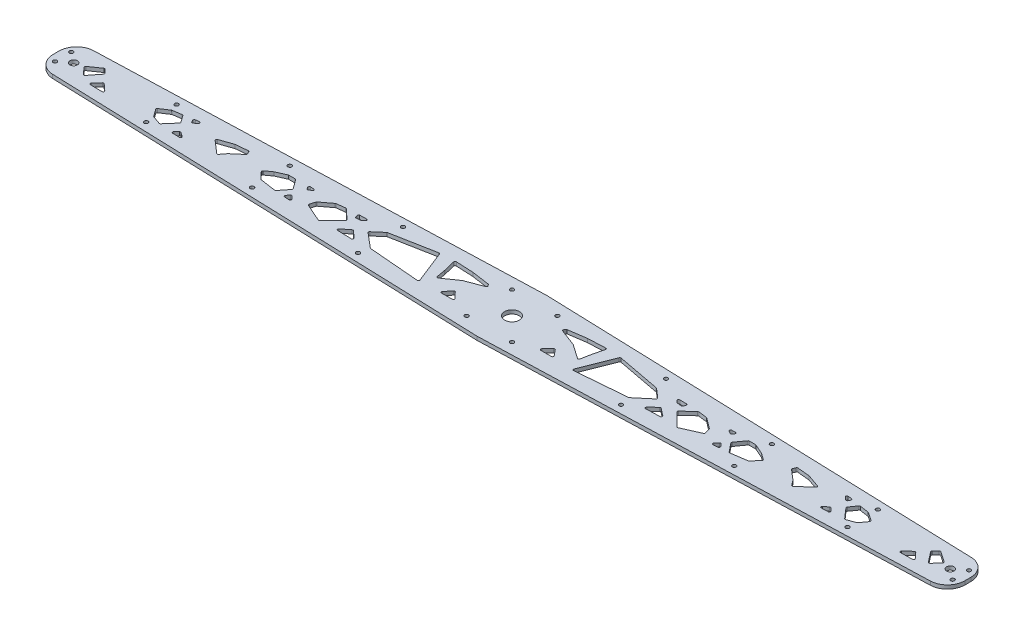
from build123d import *

# Parameters (mm, degrees)
BOSS_EXTRUDE1_DEPTH = 3.18
SKETCH3_R           = 6.35
SKETCH3_R_2         = 3.175
SKETCH3_R_3         = 1.65
CUT_EXTRUDE1_DEPTH  = 4.18
CUT_EXTRUDE8_DEPTH  = 4.18


with BuildPart() as part:
    # Sketch2 → Boss-Extrude1 (new body)
    with BuildSketch(Plane(origin=(0, 0, 0), x_dir=(1, 0, 0), z_dir=(0, 1, 0))):
        with BuildLine():
            Line((-375, 17.5), (0, 30))
            Line((0, 30), (375, 17.5))
            Line((375, 17.5), (375.499722453, 17.483342585))
            ThreePointArc((375.499722453, 17.483342585), (385.781832794, 12.920095592), (390, 2.49166898))
            Line((390, 2.49166898), (390, -2.49166898))
            ThreePointArc((390, -2.49166898), (385.781832794, -12.920095592), (375.499722453, -17.483342585))
            Line((375.499722453, -17.483342585), (375, -17.5))
            Line((375, -17.5), (0, -30))
            Line((0, -30), (-375, -17.5))
            Line((-375, -17.5), (-375.499722453, -17.483342585))
            ThreePointArc((-375.499722453, -17.483342585), (-385.781832794, -12.920095592), (-390, -2.49166898))
            Line((-390, -2.49166898), (-390, 2.49166898))
            ThreePointArc((-390, 2.49166898), (-385.781832794, 12.920095592), (-375.499722453, 17.483342585))
            Line((-375.499722453, 17.483342585), (-375, 17.5))
        make_face()
    extrude(amount=BOSS_EXTRUDE1_DEPTH)

    # Sketch3 → Cut-Extrude1 (cut, through all)
    with BuildSketch(Plane(origin=(0, 3.18, 0), x_dir=(1, 0, 0), z_dir=(0, 1, 0))):
        Circle(SKETCH3_R)
        with Locations((-375, 0)):
            Circle(SKETCH3_R_2)
        with Locations((-206.25, 16.125)):
            Circle(SKETCH3_R_3)
        with Locations((-112.5, -19.25)):
            Circle(SKETCH3_R_3)
        with Locations((375, 0)):
            Circle(SKETCH3_R_2)
        with Locations((-112.5, 19.25)):
            Circle(SKETCH3_R_3)
        with Locations((-206.25, -16.125)):
            Circle(SKETCH3_R_3)
        with Locations((112.5, -19.25)):
            Circle(SKETCH3_R_3)
        with Locations((112.5, 19.25)):
            Circle(SKETCH3_R_3)
        with Locations((206.25, -16.125)):
            Circle(SKETCH3_R_3)
        with Locations((206.25, 16.125)):
            Circle(SKETCH3_R_3)
        with Locations((-384, 7)):
            Circle(SKETCH3_R_3)
        with Locations((-384, -7)):
            Circle(SKETCH3_R_3)
        with Locations((384, -7)):
            Circle(SKETCH3_R_3)
        with Locations((384, 7)):
            Circle(SKETCH3_R_3)
        with Locations((-19.420687745, 19.420687745)):
            Circle(SKETCH3_R_3)
        with Locations((-19.420687745, -19.420687745)):
            Circle(SKETCH3_R_3)
        with Locations((19.420687745, -19.420687745)):
            Circle(SKETCH3_R_3)
        with Locations((19.420687745, 19.420687745)):
            Circle(SKETCH3_R_3)
        with Locations((-300, 13)):
            Circle(SKETCH3_R_3)
        with Locations((-300, -13)):
            Circle(SKETCH3_R_3)
        with Locations((300, -13)):
            Circle(SKETCH3_R_3)
        with Locations((300, 13)):
            Circle(SKETCH3_R_3)
    extrude(amount=-CUT_EXTRUDE1_DEPTH, mode=Mode.SUBTRACT)

    # Sketch11 → Cut-Extrude8 (cut, through all)
    with BuildSketch(Plane(origin=(0, 3.18, 0), x_dir=(1, 0, 0), z_dir=(0, 1, 0))):
        with BuildLine():
            Line((-46.955749346, -13.254199403), (-37.87504075, -13.254199403))
            ThreePointArc((-37.87504075, -13.254199403), (-36.95455324, -12.644971387), (-37.155639289, -11.559604889))
            Line((-37.155639289, -11.559604889), (-42.067554645, -6.472263986))
            ThreePointArc((-42.067554645, -6.472263986), (-42.827630249, -6.167686035), (-43.560434546, -6.533035888))
            Line((-43.560434546, -6.533035888), (-47.729227786, -11.620376792))
            ThreePointArc((-47.729227786, -11.620376792), (-47.859580804, -12.68208805), (-46.955749346, -13.254199403))
        make_face()
        with BuildLine():
            Line((-59.536816501, -3.515356838), (-47.468549241, 4.898167025))
            ThreePointArc((-47.468549241, 4.898167025), (-47.363497956, 4.962180575), (-47.251381641, 5.012810987))
            Line((-47.251381641, 5.012810987), (-32.914496504, 10.452279602))
            ThreePointArc((-32.914496504, 10.452279602), (-32.313794994, 11.092037289), (-32.44890253, 11.959146368))
            Line((-32.44890253, 11.959146368), (-33.152492574, 12.968368286))
            ThreePointArc((-33.152492574, 12.968368286), (-33.448046335, 13.247713619), (-33.830389761, 13.386275322))
            Line((-33.830389761, 13.386275322), (-49.020035845, 15.571979867))
            ThreePointArc((-49.020035845, 15.571979867), (-49.06816555, 15.57771866), (-49.116516797, 15.58111852))
            Line((-49.116516797, 15.58111852), (-63.942588973, 16.263044091))
            ThreePointArc((-63.942588973, 16.263044091), (-64.760029141, 15.900337127), (-64.960455814, 15.028790273))
            Line((-64.960455814, 15.028790273), (-62.531576105, 4.996583503))
            ThreePointArc((-62.531576105, 4.996583503), (-62.52527538, 4.968839122), (-62.519766476, 4.940926727))
            Line((-62.519766476, 4.940926727), (-61.092444735, -2.874685387))
            ThreePointArc((-61.092444735, -2.874685387), (-60.48952482, -3.619685515), (-59.536816501, -3.515356838))
        make_face()
        with BuildLine():
            Line((-65.867489279, -12.851084643), (-76.818791516, 14.810968515))
            ThreePointArc((-76.818791516, 14.810968515), (-77.266092019, 15.318773143), (-77.93434379, 15.42546359))
            Line((-77.93434379, 15.42546359), (-114.979478259, 8.421844862))
            ThreePointArc((-114.979478259, 8.421844862), (-115.227740664, 8.340150133), (-115.44635537, 8.196916545))
            Line((-115.44635537, 8.196916545), (-123.167009838, 1.546451805))
            ThreePointArc((-123.167009838, 1.546451805), (-123.514354617, 0.783798146), (-123.159419133, 0.024647435))
            Line((-123.159419133, 0.024647435), (-110.862565184, -10.35581369))
            ThreePointArc((-110.862565184, -10.35581369), (-110.599754836, -10.515737447), (-110.300767263, -10.588203424))
            Line((-110.300767263, -10.588203424), (-66.880530036, -14.21571199))
            ThreePointArc((-66.880530036, -14.21571199), (-65.994339866, -13.81524887), (-65.867489279, -12.851084643))
        make_face()
        with BuildLine():
            Line((-138.500363881, -9.512051857), (-132.205638285, -4.609617592))
            ThreePointArc((-132.205638285, -4.609617592), (-131.548188505, -4.399497492), (-130.911222966, -4.665327458))
            Line((-130.911222966, -4.665327458), (-125.244008956, -9.920736989))
            ThreePointArc((-125.244008956, -9.920736989), (-124.998535496, -11.032881643), (-125.953468681, -11.653547063))
            Line((-125.953468681, -11.653547063), (-137.915408287, -11.300571796))
            ThreePointArc((-137.915408287, -11.300571796), (-138.836369454, -10.611864392), (-138.500363881, -9.512051857))
        make_face()
        with BuildLine():
            Line((-139.739839999, 9.466665143), (-133.930891567, 9.592555667))
            ThreePointArc((-133.930891567, 9.592555667), (-132.974208512, 8.947395111), (-133.262475942, 7.83008741))
            Line((-133.262475942, 7.83008741), (-134.995827799, 6.360257908))
            ThreePointArc((-134.995827799, 6.360257908), (-135.241086847, 6.207097438), (-135.519914513, 6.130512433))
            Line((-135.519914513, 6.130512433), (-138.979079647, 5.70297517))
            ThreePointArc((-138.979079647, 5.70297517), (-139.629939754, 5.846302376), (-140.046194638, 6.366776619))
            Line((-140.046194638, 6.366776619), (-140.662626079, 8.138252861))
            ThreePointArc((-140.662626079, 8.138252861), (-140.539462824, 9.037411465), (-139.739839999, 9.466665143))
        make_face()
        with BuildLine():
            Line((-141.869121283, 0.703843181), (-150.293270264, 8.561291761))
            ThreePointArc((-150.293270264, 8.561291761), (-150.668059683, 8.78163118), (-151.100932501, 8.822099584))
            Line((-151.100932501, 8.822099584), (-158.46185294, 7.890337503))
            ThreePointArc((-158.46185294, 7.890337503), (-158.713075968, 7.824547363), (-158.938886877, 7.696286749))
            Line((-158.938886877, 7.696286749), (-167.835601055, 0.978159169))
            ThreePointArc((-167.835601055, 0.978159169), (-168.05379305, 0.751333346), (-168.190677878, 0.467925082))
            Line((-168.190677878, 0.467925082), (-169.532071457, -3.995753156))
            ThreePointArc((-169.532071457, -3.995753156), (-169.482672907, -4.701887684), (-168.978159747, -5.198408239))
            Line((-168.978159747, -5.198408239), (-153.825057905, -11.886351336))
            ThreePointArc((-153.825057905, -11.886351336), (-153.235786306, -11.95414059), (-152.711777672, -11.676199315))
            Line((-152.711777672, -11.676199315), (-141.841702337, -0.7321369))
            ThreePointArc((-141.841702337, -0.7321369), (-141.551385579, -0.00834171), (-141.869121283, 0.703843181))
        make_face()
        with BuildLine():
            Line((-182.755031755, -5.299067981), (-180.579398257, -7.823296737))
            ThreePointArc((-180.579398257, -7.823296737), (-180.443829145, -8.926135869), (-181.410839593, -9.473423661))
            Line((-181.410839593, -9.473423661), (-185.439828424, -9.174588009))
            ThreePointArc((-185.439828424, -9.174588009), (-186.28646803, -8.567815923), (-186.134274883, -7.537375127))
            Line((-186.134274883, -7.537375127), (-184.280919551, -5.311982023))
            ThreePointArc((-184.280919551, -5.311982023), (-183.520967893, -4.951970116), (-182.755031755, -5.299067981))
        make_face()
        with BuildLine():
            Line((-180.487436758, 6.129209035), (-178.34410904, 7.407639798))
            ThreePointArc((-178.34410904, 7.407639798), (-177.88764506, 8.514589055), (-178.82004379, 9.265807153))
            Line((-178.82004379, 9.265807153), (-181.742763405, 9.372060074))
            ThreePointArc((-181.742763405, 9.372060074), (-182.63306088, 8.893046831), (-182.650532608, 7.882216471))
            Line((-182.650532608, 7.882216471), (-181.871140711, 6.497532787))
            ThreePointArc((-181.871140711, 6.497532787), (-181.256931343, 6.02168626), (-180.487436758, 6.129209035))
        make_face()
        with BuildLine():
            Line((-193.789039066, -8.041405278), (-187.852068886, -0.594564861))
            ThreePointArc((-187.852068886, -0.594564861), (-187.634249822, 0.00587827), (-187.824300509, 0.615679742))
            Line((-187.824300509, 0.615679742), (-193.434660528, 8.356209406))
            ThreePointArc((-193.434660528, 8.356209406), (-193.789848688, 8.660094071), (-194.244346721, 8.76934633))
            Line((-194.244346721, 8.76934633), (-199.70292112, 8.76934633))
            ThreePointArc((-199.70292112, 8.76934633), (-199.909407573, 8.74779579), (-200.106994237, 8.68407302))
            Line((-200.106994237, 8.68407302), (-208.420259277, 5.011755427))
            ThreePointArc((-208.420259277, 5.011755427), (-208.514430087, 4.964065639), (-208.603049236, 4.90671493))
            Line((-208.603049236, 4.90671493), (-213.928370429, 1.046905536))
            ThreePointArc((-213.928370429, 1.046905536), (-214.336865254, 0.333462004), (-214.072627838, -0.445029026))
            Line((-214.072627838, -0.445029026), (-208.756796528, -6.141654092))
            ThreePointArc((-208.756796528, -6.141654092), (-208.489458004, -6.345355097), (-208.169728821, -6.448975729))
            Line((-208.169728821, -6.448975729), (-194.715009659, -8.407593757))
            ThreePointArc((-194.715009659, -8.407593757), (-194.203204992, -8.347947697), (-193.789039066, -8.041405278))
        make_face()
        with BuildLine():
            Line((-256.671139357, 4.718751255), (-245.67497638, 8.531374359))
            ThreePointArc((-245.67497638, 8.531374359), (-245.560909702, 8.563492446), (-245.443844553, 8.581891611))
            Line((-245.443844553, 8.581891611), (-235.114669132, 9.582900663))
            ThreePointArc((-235.114669132, 9.582900663), (-234.507333866, 9.447217919), (-234.097843596, 8.978620382))
            Line((-234.097843596, 8.978620382), (-233.190223738, 6.842502951))
            ThreePointArc((-233.190223738, 6.842502951), (-233.137214687, 6.222230535), (-233.461435256, 5.690790178))
            Line((-233.461435256, 5.690790178), (-241.684376578, -1.326788715))
            ThreePointArc((-241.684376578, -1.326788715), (-241.760643057, -1.399139955), (-241.828892701, -1.479097843))
            Line((-241.828892701, -1.479097843), (-245.184318041, -5.856705737))
            ThreePointArc((-245.184318041, -5.856705737), (-245.877859549, -6.24333317), (-246.634530886, -6.002648555))
            Line((-246.634530886, -6.002648555), (-257.000090234, 3.019641763))
            ThreePointArc((-257.000090234, 3.019641763), (-257.325318633, 3.964004117), (-256.671139357, 4.718751255))
        make_face()
        with BuildLine():
            Line((-281.137073769, -8.153694647), (-278.818258184, -5.834879062))
            ThreePointArc((-278.818258184, -5.834879062), (-278.197065936, -5.545683332), (-277.535535613, -5.724265559))
            Line((-277.535535613, -5.724265559), (-273.998540412, -8.214053722))
            ThreePointArc((-273.998540412, -8.214053722), (-273.625321962, -9.34754859), (-274.603340844, -10.031348044))
            Line((-274.603340844, -10.031348044), (-280.459151631, -9.860375466))
            ThreePointArc((-280.459151631, -9.860375466), (-281.359332965, -9.229961123), (-281.137073769, -8.153694647))
        make_face()
        with BuildLine():
            Line((-280.723932944, 9.802625591), (-277.488789213, 10.127315226))
            ThreePointArc((-277.488789213, 10.127315226), (-276.467186027, 9.520118535), (-276.747414613, 8.365201728))
            Line((-276.747414613, 8.365201728), (-279.104707894, 6.393867718))
            ThreePointArc((-279.104707894, 6.393867718), (-279.937308548, 6.179406901), (-280.628653906, 6.690541801))
            Line((-280.628653906, 6.690541801), (-281.506504356, 8.337186176))
            ThreePointArc((-281.506504356, 8.337186176), (-281.506173293, 9.278682803), (-280.723932944, 9.802625591))
        make_face()
        with BuildLine():
            Line((-290.168206163, 8.025157975), (-297.744296977, 6.8636667))
            ThreePointArc((-297.744296977, 6.8636667), (-297.954032467, 6.807674803), (-298.146743207, 6.707741631))
            Line((-298.146743207, 6.707741631), (-305.204875906, 2.011065969))
            ThreePointArc((-305.204875906, 2.011065969), (-305.634726846, 1.357607704), (-305.462686612, 0.594599387))
            Line((-305.462686612, 0.594599387), (-301.147906841, -5.403825691))
            ThreePointArc((-301.147906841, -5.403825691), (-300.937309283, -5.618984629), (-300.672216228, -5.761709442))
            Line((-300.672216228, -5.761709442), (-293.667939867, -8.26130378))
            ThreePointArc((-293.667939867, -8.26130378), (-293.079312884, -8.287070959), (-292.57834751, -7.976942974))
            Line((-292.57834751, -7.976942974), (-285.112364404, 0.57945318))
            ThreePointArc((-285.112364404, 0.57945318), (-284.867009214, 1.188798819), (-285.052655481, 1.818907335))
            Line((-285.052655481, 1.818907335), (-289.203471205, 7.618697534))
            ThreePointArc((-289.203471205, 7.618697534), (-289.628401701, 7.958254589), (-290.168206163, 8.025157975))
        make_face()
        with BuildLine():
            Line((-360.721388989, -4.456205516), (-353.816399288, 4.292749779))
            ThreePointArc((-353.816399288, 4.292749779), (-353.602294182, 4.955196144), (-353.872418696, 5.596841629))
            Line((-353.872418696, 5.596841629), (-356.779527483, 8.692466622))
            ThreePointArc((-356.779527483, 8.692466622), (-357.402501606, 9.002272333), (-358.07677814, 8.830727899))
            Line((-358.07677814, 8.830727899), (-367.037687971, 2.641731163))
            ThreePointArc((-367.037687971, 2.641731163), (-367.461830786, 1.941643396), (-367.221019381, 1.159320012))
            Line((-367.221019381, 1.159320012), (-362.257990463, -4.496263538))
            ThreePointArc((-362.257990463, -4.496263538), (-361.480302142, -4.836336586), (-360.721388989, -4.456205516))
        make_face()
        with BuildLine():
            Line((-352.372806931, -7.394203651), (-347.919490428, -2.485222451))
            ThreePointArc((-347.919490428, -2.485222451), (-347.227457966, -2.158301193), (-346.506948881, -2.416473802))
            Line((-346.506948881, -2.416473802), (-340.919616542, -7.485175085))
            ThreePointArc((-340.919616542, -7.485175085), (-340.661495607, -8.593335713), (-341.607418325, -9.225693685))
            Line((-341.607418325, -9.225693685), (-351.648067167, -9.065973602))
            ThreePointArc((-351.648067167, -9.065973602), (-352.549656155, -8.463848976), (-352.372806931, -7.394203651))
        make_face()
        with BuildLine():
            Line((37.155639289, -11.559604889), (42.067554645, -6.472263986))
            ThreePointArc((42.067554645, -6.472263986), (42.827630249, -6.167686035), (43.560434546, -6.533035888))
            Line((43.560434546, -6.533035888), (47.729227786, -11.620376792))
            ThreePointArc((47.729227786, -11.620376792), (47.859580804, -12.68208805), (46.955749346, -13.254199403))
            Line((46.955749346, -13.254199403), (37.87504075, -13.254199403))
            ThreePointArc((37.87504075, -13.254199403), (36.95455324, -12.644971387), (37.155639289, -11.559604889))
        make_face()
        with BuildLine():
            Line((64.960455814, 15.028790273), (62.531576105, 4.996583503))
            ThreePointArc((62.531576105, 4.996583503), (62.52527538, 4.968839122), (62.519766476, 4.940926727))
            Line((62.519766476, 4.940926727), (61.092444735, -2.874685387))
            ThreePointArc((61.092444735, -2.874685387), (60.48952482, -3.619685515), (59.536816501, -3.515356838))
            Line((59.536816501, -3.515356838), (47.468549241, 4.898167025))
            ThreePointArc((47.468549241, 4.898167025), (47.363497956, 4.962180575), (47.251381641, 5.012810987))
            Line((47.251381641, 5.012810987), (32.914496504, 10.452279602))
            ThreePointArc((32.914496504, 10.452279602), (32.313794994, 11.092037289), (32.44890253, 11.959146368))
            Line((32.44890253, 11.959146368), (33.152492574, 12.968368286))
            ThreePointArc((33.152492574, 12.968368286), (33.448046335, 13.247713619), (33.830389761, 13.386275322))
            Line((33.830389761, 13.386275322), (49.020035845, 15.571979867))
            ThreePointArc((49.020035845, 15.571979867), (49.06816555, 15.57771866), (49.116516797, 15.58111852))
            Line((49.116516797, 15.58111852), (63.942588973, 16.263044091))
            ThreePointArc((63.942588973, 16.263044091), (64.760029141, 15.900337127), (64.960455814, 15.028790273))
        make_face()
        with BuildLine():
            Line((123.159419133, 0.024647435), (110.862565184, -10.35581369))
            ThreePointArc((110.862565184, -10.35581369), (110.599754836, -10.515737447), (110.300767263, -10.588203424))
            Line((110.300767263, -10.588203424), (66.880530036, -14.21571199))
            ThreePointArc((66.880530036, -14.21571199), (65.994339866, -13.81524887), (65.867489279, -12.851084643))
            Line((65.867489279, -12.851084643), (76.818791516, 14.810968515))
            ThreePointArc((76.818791516, 14.810968515), (77.266092019, 15.318773143), (77.93434379, 15.42546359))
            Line((77.93434379, 15.42546359), (114.979478259, 8.421844862))
            ThreePointArc((114.979478259, 8.421844862), (115.227740664, 8.340150133), (115.44635537, 8.196916545))
            Line((115.44635537, 8.196916545), (123.167009838, 1.546451805))
            ThreePointArc((123.167009838, 1.546451805), (123.514354617, 0.783798146), (123.159419133, 0.024647435))
        make_face()
        with BuildLine():
            Line((135.519914513, 6.130512433), (138.979079647, 5.70297517))
            ThreePointArc((138.979079647, 5.70297517), (139.629939754, 5.846302376), (140.046194638, 6.366776619))
            Line((140.046194638, 6.366776619), (140.662626079, 8.138252861))
            ThreePointArc((140.662626079, 8.138252861), (140.539462824, 9.037411465), (139.739839999, 9.466665143))
            Line((139.739839999, 9.466665143), (133.930891567, 9.592555667))
            ThreePointArc((133.930891567, 9.592555667), (132.974208512, 8.947395111), (133.262475942, 7.83008741))
            Line((133.262475942, 7.83008741), (134.995827799, 6.360257908))
            ThreePointArc((134.995827799, 6.360257908), (135.241086847, 6.207097438), (135.519914513, 6.130512433))
        make_face()
        with BuildLine():
            Line((130.911222966, -4.665327458), (125.244008956, -9.920736989))
            ThreePointArc((125.244008956, -9.920736989), (124.998535496, -11.032881643), (125.953468681, -11.653547063))
            Line((125.953468681, -11.653547063), (137.915408287, -11.300571796))
            ThreePointArc((137.915408287, -11.300571796), (138.836369454, -10.611864392), (138.500363881, -9.512051857))
            Line((138.500363881, -9.512051857), (132.205638285, -4.609617592))
            ThreePointArc((132.205638285, -4.609617592), (131.548188505, -4.399497492), (130.911222966, -4.665327458))
        make_face()
        with BuildLine():
            Line((168.978159747, -5.198408239), (153.825057905, -11.886351336))
            ThreePointArc((153.825057905, -11.886351336), (153.235786306, -11.95414059), (152.711777672, -11.676199315))
            Line((152.711777672, -11.676199315), (141.841702337, -0.7321369))
            ThreePointArc((141.841702337, -0.7321369), (141.551385579, -0.00834171), (141.869121283, 0.703843181))
            Line((141.869121283, 0.703843181), (150.293270264, 8.561291761))
            ThreePointArc((150.293270264, 8.561291761), (150.668059683, 8.78163118), (151.100932501, 8.822099584))
            Line((151.100932501, 8.822099584), (158.46185294, 7.890337503))
            ThreePointArc((158.46185294, 7.890337503), (158.713075968, 7.824547363), (158.938886877, 7.696286749))
            Line((158.938886877, 7.696286749), (167.835601055, 0.978159169))
            ThreePointArc((167.835601055, 0.978159169), (168.05379305, 0.751333346), (168.190677878, 0.467925082))
            Line((168.190677878, 0.467925082), (169.532071457, -3.995753156))
            ThreePointArc((169.532071457, -3.995753156), (169.482672907, -4.701887684), (168.978159747, -5.198408239))
        make_face()
        with BuildLine():
            Line((181.871140711, 6.497532787), (182.650532608, 7.882216471))
            ThreePointArc((182.650532608, 7.882216471), (182.63306088, 8.893046831), (181.742763405, 9.372060074))
            Line((181.742763405, 9.372060074), (178.82004379, 9.265807153))
            ThreePointArc((178.82004379, 9.265807153), (177.88764506, 8.514589055), (178.34410904, 7.407639798))
            Line((178.34410904, 7.407639798), (180.487436758, 6.129209035))
            ThreePointArc((180.487436758, 6.129209035), (181.256931343, 6.02168626), (181.871140711, 6.497532787))
        make_face()
        with BuildLine():
            Line((181.410839593, -9.473423661), (185.439828424, -9.174588009))
            ThreePointArc((185.439828424, -9.174588009), (186.28646803, -8.567815923), (186.134274883, -7.537375127))
            Line((186.134274883, -7.537375127), (184.280919551, -5.311982023))
            ThreePointArc((184.280919551, -5.311982023), (183.520967893, -4.951970116), (182.755031755, -5.299067981))
            Line((182.755031755, -5.299067981), (180.579398257, -7.823296737))
            ThreePointArc((180.579398257, -7.823296737), (180.443829145, -8.926135869), (181.410839593, -9.473423661))
        make_face()
        with BuildLine():
            Line((214.072627838, -0.445029026), (208.756796528, -6.141654092))
            ThreePointArc((208.756796528, -6.141654092), (208.489458004, -6.345355097), (208.169728821, -6.448975729))
            Line((208.169728821, -6.448975729), (194.715009659, -8.407593757))
            ThreePointArc((194.715009659, -8.407593757), (194.203204992, -8.347947697), (193.789039066, -8.041405278))
            Line((193.789039066, -8.041405278), (187.852068886, -0.594564861))
            ThreePointArc((187.852068886, -0.594564861), (187.634249822, 0.00587827), (187.824300509, 0.615679742))
            Line((187.824300509, 0.615679742), (193.434660528, 8.356209406))
            ThreePointArc((193.434660528, 8.356209406), (193.789848688, 8.660094071), (194.244346721, 8.76934633))
            Line((194.244346721, 8.76934633), (199.70292112, 8.76934633))
            ThreePointArc((199.70292112, 8.76934633), (199.909407573, 8.74779579), (200.106994237, 8.68407302))
            Line((200.106994237, 8.68407302), (208.420259277, 5.011755427))
            ThreePointArc((208.420259277, 5.011755427), (208.514430087, 4.964065639), (208.603049236, 4.90671493))
            Line((208.603049236, 4.90671493), (213.928370429, 1.046905536))
            ThreePointArc((213.928370429, 1.046905536), (214.336865254, 0.333462004), (214.072627838, -0.445029026))
        make_face()
        with BuildLine():
            Line((241.828892701, -1.479097843), (245.184318041, -5.856705737))
            ThreePointArc((245.184318041, -5.856705737), (245.877859549, -6.24333317), (246.634530886, -6.002648555))
            Line((246.634530886, -6.002648555), (257.000090234, 3.019641763))
            ThreePointArc((257.000090234, 3.019641763), (257.325318633, 3.964004117), (256.671139357, 4.718751255))
            Line((256.671139357, 4.718751255), (245.67497638, 8.531374359))
            ThreePointArc((245.67497638, 8.531374359), (245.560909702, 8.563492446), (245.443844553, 8.581891611))
            Line((245.443844553, 8.581891611), (235.114669132, 9.582900663))
            ThreePointArc((235.114669132, 9.582900663), (234.507333866, 9.447217919), (234.097843596, 8.978620382))
            Line((234.097843596, 8.978620382), (233.190223738, 6.842502951))
            ThreePointArc((233.190223738, 6.842502951), (233.137214687, 6.222230535), (233.461435256, 5.690790178))
            Line((233.461435256, 5.690790178), (241.684376578, -1.326788715))
            ThreePointArc((241.684376578, -1.326788715), (241.760643057, -1.399139955), (241.828892701, -1.479097843))
        make_face()
        with BuildLine():
            Line((276.747414613, 8.365201728), (279.104707894, 6.393867718))
            ThreePointArc((279.104707894, 6.393867718), (279.937308548, 6.179406901), (280.628653906, 6.690541801))
            Line((280.628653906, 6.690541801), (281.506504356, 8.337186176))
            ThreePointArc((281.506504356, 8.337186176), (281.506173293, 9.278682803), (280.723932944, 9.802625591))
            Line((280.723932944, 9.802625591), (277.488789213, 10.127315226))
            ThreePointArc((277.488789213, 10.127315226), (276.467186027, 9.520118535), (276.747414613, 8.365201728))
        make_face()
        with BuildLine():
            Line((277.535535613, -5.724265559), (273.998540412, -8.214053722))
            ThreePointArc((273.998540412, -8.214053722), (273.625321962, -9.34754859), (274.603340844, -10.031348044))
            Line((274.603340844, -10.031348044), (280.459151631, -9.860375466))
            ThreePointArc((280.459151631, -9.860375466), (281.359332965, -9.229961123), (281.137073769, -8.153694647))
            Line((281.137073769, -8.153694647), (278.818258184, -5.834879062))
            ThreePointArc((278.818258184, -5.834879062), (278.197065936, -5.545683332), (277.535535613, -5.724265559))
        make_face()
        with BuildLine():
            Line((292.57834751, -7.976942974), (285.112364404, 0.57945318))
            ThreePointArc((285.112364404, 0.57945318), (284.867009214, 1.188798819), (285.052655481, 1.818907335))
            Line((285.052655481, 1.818907335), (289.203471205, 7.618697534))
            ThreePointArc((289.203471205, 7.618697534), (289.628401701, 7.958254589), (290.168206163, 8.025157975))
            Line((290.168206163, 8.025157975), (297.744296977, 6.8636667))
            ThreePointArc((297.744296977, 6.8636667), (297.954032467, 6.807674803), (298.146743207, 6.707741631))
            Line((298.146743207, 6.707741631), (305.204875906, 2.011065969))
            ThreePointArc((305.204875906, 2.011065969), (305.634726846, 1.357607704), (305.462686612, 0.594599387))
            Line((305.462686612, 0.594599387), (301.147906841, -5.403825691))
            ThreePointArc((301.147906841, -5.403825691), (300.937309283, -5.618984629), (300.672216228, -5.761709442))
            Line((300.672216228, -5.761709442), (293.667939867, -8.26130378))
            ThreePointArc((293.667939867, -8.26130378), (293.079312884, -8.287070959), (292.57834751, -7.976942974))
        make_face()
        with BuildLine():
            Line((358.07677814, 8.830727899), (367.037687971, 2.641731163))
            ThreePointArc((367.037687971, 2.641731163), (367.461830786, 1.941643396), (367.221019381, 1.159320012))
            Line((367.221019381, 1.159320012), (362.257990463, -4.496263538))
            ThreePointArc((362.257990463, -4.496263538), (361.480302142, -4.836336586), (360.721388989, -4.456205516))
            Line((360.721388989, -4.456205516), (353.816399288, 4.292749779))
            ThreePointArc((353.816399288, 4.292749779), (353.602294182, 4.955196144), (353.872418696, 5.596841629))
            Line((353.872418696, 5.596841629), (356.779527483, 8.692466622))
            ThreePointArc((356.779527483, 8.692466622), (357.402501606, 9.002272333), (358.07677814, 8.830727899))
        make_face()
        with BuildLine():
            Line((346.506948881, -2.416473802), (340.919616542, -7.485175085))
            ThreePointArc((340.919616542, -7.485175085), (340.661495607, -8.593335713), (341.607418325, -9.225693685))
            Line((341.607418325, -9.225693685), (351.648067167, -9.065973602))
            ThreePointArc((351.648067167, -9.065973602), (352.549656155, -8.463848976), (352.372806931, -7.394203651))
            Line((352.372806931, -7.394203651), (347.919490428, -2.485222451))
            ThreePointArc((347.919490428, -2.485222451), (347.227457966, -2.158301193), (346.506948881, -2.416473802))
        make_face()
    extrude(amount=-CUT_EXTRUDE8_DEPTH, mode=Mode.SUBTRACT)


solid = part.part
